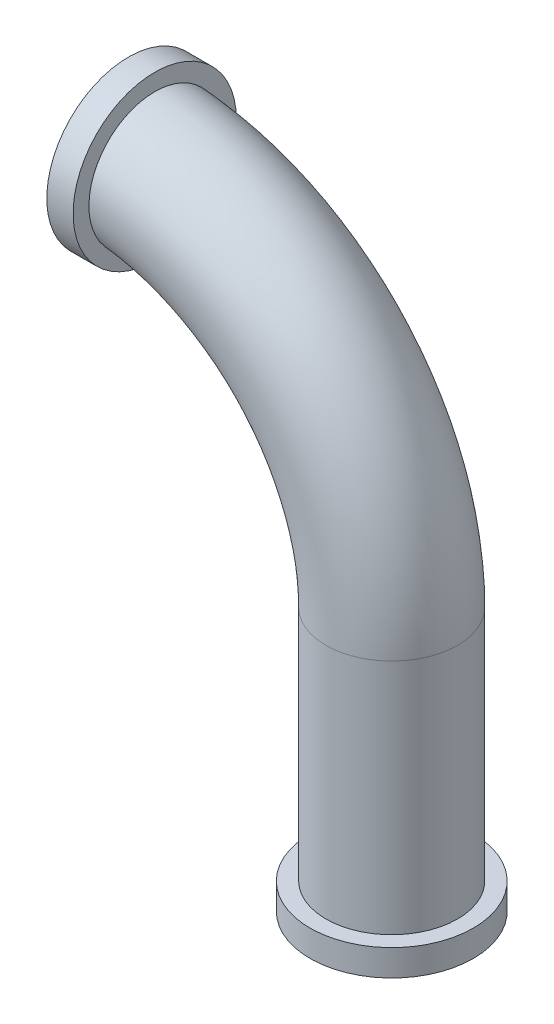
from build123d import *

# Parameters (mm, degrees)
IZIM3_R   = 0.25
IZIM3_R_2 = 0.2
IZIM4_R   = 0.31
IZIM4_R_2 = 0.21
IZIM5_R   = 0.31
IZIM5_R_2 = 0.21


with BuildPart() as part:
    # Süpür-İnce1: sweep along a path in Çizim1
    with BuildLine(Plane.XY) as s_p_r_nce1_path:
        Line((1, -1), (1, 0))
        ThreePointArc((1, 0), (0.707106781, 0.707106781), (0, 1))
    # Çizim3 → Süpür-İnce1 (sweep)
    with BuildSketch(Plane(origin=(0, 0, 0), x_dir=(0, 0, -1), z_dir=(1, 0, 0))):
        with Locations((0, 1)):
            Circle(IZIM3_R)
        with Locations((0, 1)):
            Circle(IZIM3_R_2, mode=Mode.SUBTRACT)
    sweep(path=s_p_r_nce1_path.line)

    # Süpür-İnce2: sweep along a path in Çizim7
    with BuildLine(Plane.XY) as s_p_r_nce2_path:
        Line((0, 1), (0.1, 1))
    # Çizim4 → Süpür-İnce2 (sweep)
    with BuildSketch(Plane(origin=(0, 0, 0), x_dir=(0, 0, -1), z_dir=(1, 0, 0))):
        with Locations((0, 1)):
            Circle(IZIM4_R)
        with Locations((0, 1)):
            Circle(IZIM4_R_2, mode=Mode.SUBTRACT)
    sweep(path=s_p_r_nce2_path.line)

    # Süpür-İnce3: sweep along a path in Çizim6
    with BuildLine(Plane.XY) as s_p_r_nce3_path:
        Line((1, -1), (1, -0.9))
    # Çizim5 → Süpür-İnce3 (sweep)
    with BuildSketch(Plane(origin=(0, -1, 0), x_dir=(-1, 0, 0), z_dir=(0, -1, 0))):
        with Locations((-1, 0)):
            Circle(IZIM5_R)
        with Locations((-1, 0)):
            Circle(IZIM5_R_2, mode=Mode.SUBTRACT)
    sweep(path=s_p_r_nce3_path.line)


solid = part.part
